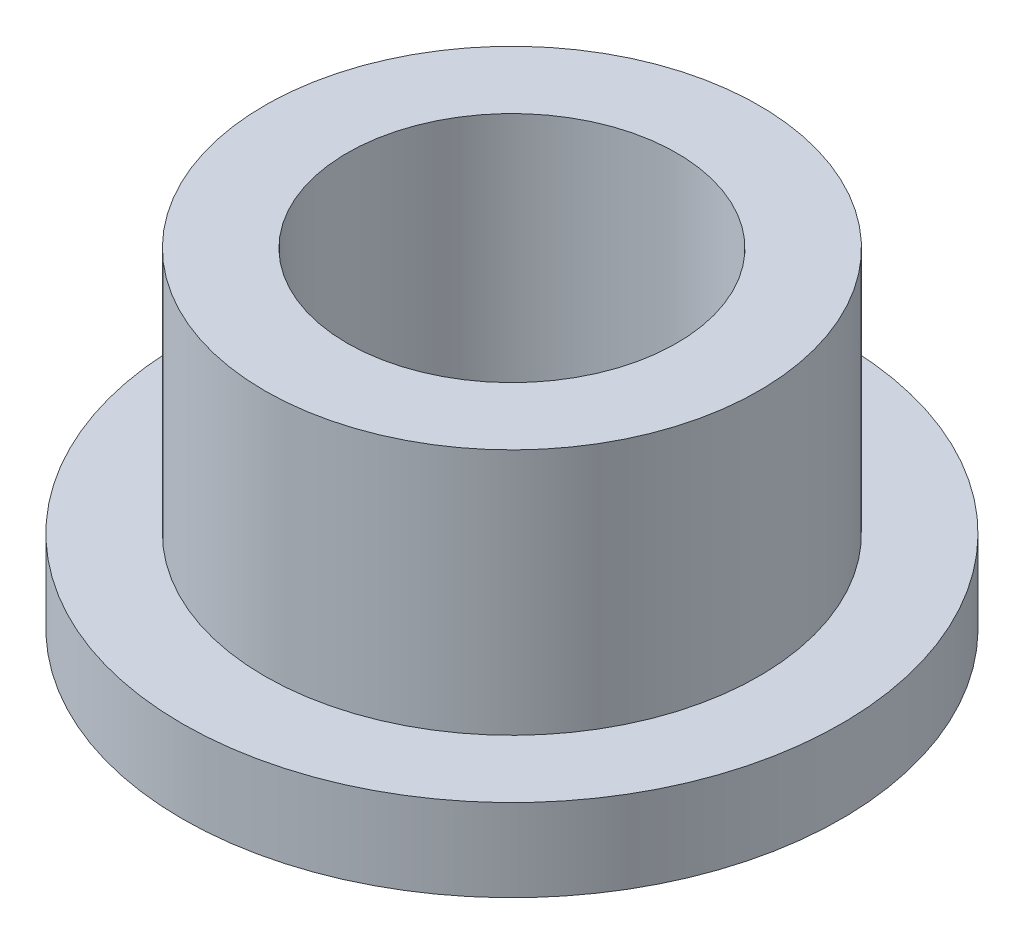
from build123d import *

# Parameters (mm, degrees)
SKETCH2_R           = 4.7625
SKETCH2_R_2         = 3.175
BOSS_EXTRUDE1_DEPTH = 6.35
SKETCH3_R           = 6.35
SKETCH3_R_2         = 4.7625
BOSS_EXTRUDE2_DEPTH = 1.5875


with BuildPart() as part:
    # Sketch2 → Boss-Extrude1 (new body)
    with BuildSketch(Plane(origin=(0, 0, 0), x_dir=(1, 0, 0), z_dir=(0, 1, 0))):
        Circle(SKETCH2_R)
        Circle(SKETCH2_R_2, mode=Mode.SUBTRACT)
    extrude(amount=BOSS_EXTRUDE1_DEPTH)

    # Sketch3 → Boss-Extrude2 (add)
    with BuildSketch(Plane(origin=(0, 0, 0), x_dir=(1, 0, 0), z_dir=(0, 1, 0))):
        Circle(SKETCH3_R)
        Circle(SKETCH3_R_2, mode=Mode.SUBTRACT)
    extrude(amount=BOSS_EXTRUDE2_DEPTH)


solid = part.part
